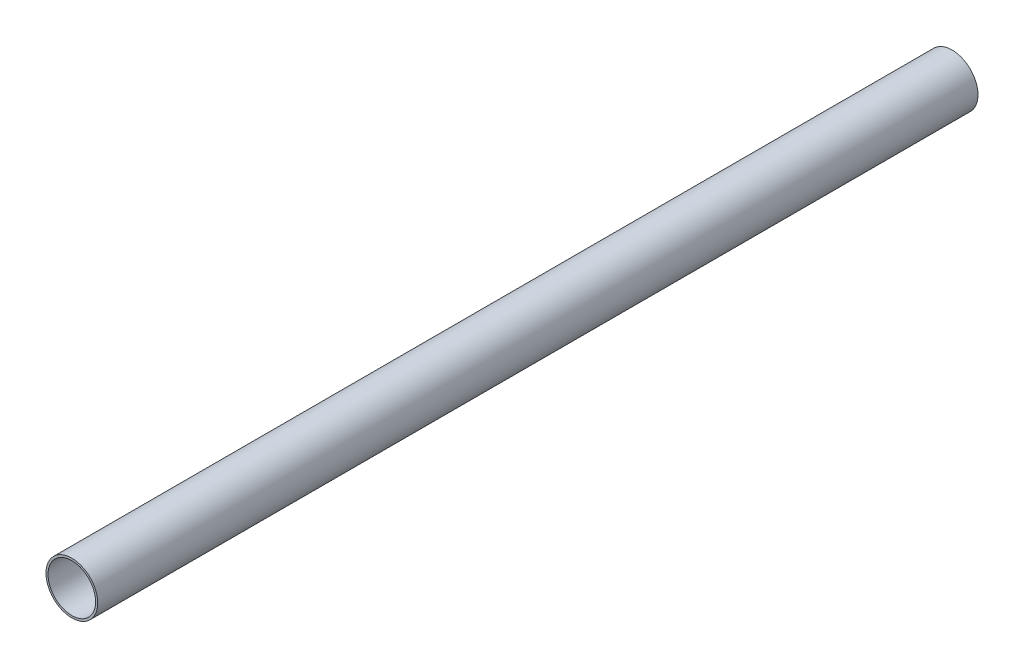
from build123d import *

# Parameters (mm, degrees)
SKETCH_1_R      = 50
SKETCH_1_R_2    = 46
EXTRUDE_1_DEPTH = 1700


with BuildPart() as part:
    # Эскиз1 → Бобышка-Вытянуть1 (new body)
    with BuildSketch(Plane.XY):
        Circle(SKETCH_1_R)
        Circle(SKETCH_1_R_2, mode=Mode.SUBTRACT)
    extrude(amount=EXTRUDE_1_DEPTH)


solid = part.part
